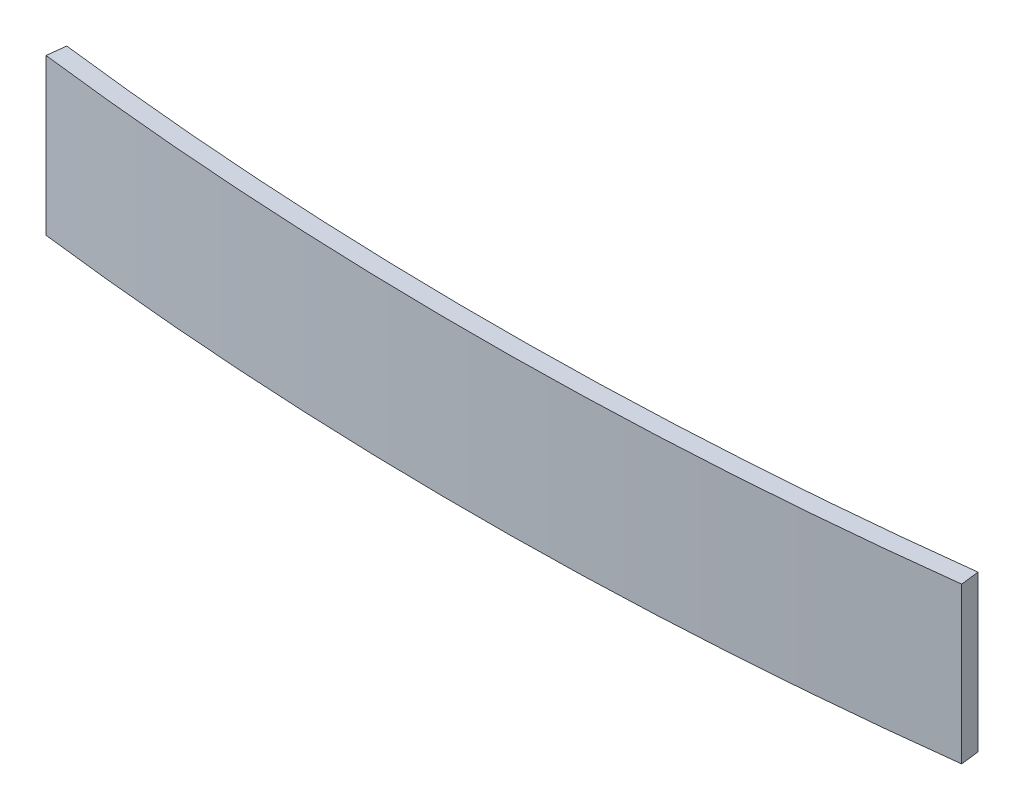
from build123d import *

# Parameters (mm, degrees)
BOSS_EXTRUDE1_DEPTH = 25


with BuildPart() as part:
    # Sketch2 → Boss-Extrude1 (new body)
    with BuildSketch(Plane(origin=(0, 0, 0), x_dir=(1, 0, 0), z_dir=(0, 1, 0))):
        with BuildLine():
            Line((-73.115286629, 2.629690485), (-72.75191537, 5.607602728))
            ThreePointArc((-72.75191537, 5.607602728), (0.384713371, 1.161945481), (73.521342111, 5.607602728))
            Line((73.521342111, 5.607602728), (73.884713371, 2.629690485))
            ThreePointArc((73.884713371, 2.629690485), (0.384713371, -1.838054519), (-73.115286629, 2.629690485))
        make_face()
    extrude(amount=BOSS_EXTRUDE1_DEPTH)


solid = part.part
